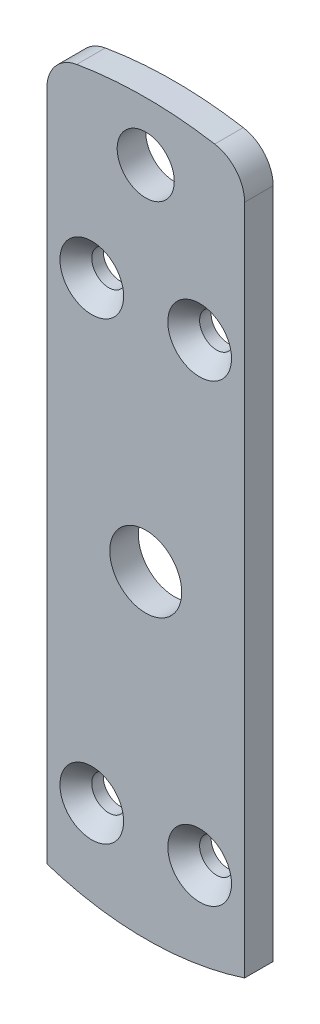
from build123d import *

# Parameters (mm, degrees)
SKETCH1_R                                      = 4
SKETCH1_R_2                                    = 3.175
BOSS_EXTRUDE1_DEPTH                            = 3.175
CSK_FOR_6_FLAT_HEAD_MACHINE_SCREW1_D           = 3.7973
CSK_FOR_6_FLAT_HEAD_MACHINE_SCREW1_DEPTH       = 10.973
CSK_FOR_6_FLAT_HEAD_MACHINE_SCREW1_CSINK_D     = 7.0866
CSK_FOR_6_FLAT_HEAD_MACHINE_SCREW1_CSINK_ANGLE = 82
CSK_FOR_6_FLAT_HEAD_MACHINE_SCREW1_TIP         = 1.140824014
FILLET1_R                                      = 4


with BuildPart() as part:
    # Sketch1 → Boss-Extrude1 (new body)
    with BuildSketch(Plane.XY):
        with BuildLine():
            Line((11, 44.330639799), (11, -33.647585352))
            ThreePointArc((11, -33.647585352), (0, -35.4), (-11, -33.647585352))
            Line((-11, -33.647585352), (-11, 44.330639799))
            ThreePointArc((-11, 44.330639799), (0, 45.675), (11, 44.330639799))
        make_face()
        Circle(SKETCH1_R, mode=Mode.SUBTRACT)
        with Locations((0, 39.175)):
            Circle(SKETCH1_R_2, mode=Mode.SUBTRACT)
    extrude(amount=BOSS_EXTRUDE1_DEPTH)

    # CSK for _6 Flat Head Machine Screw1
    with Locations(Plane.XY.offset(3.175)):
        with Locations((-6, 25.298221281), (-6, -25.298221281), (6, 25.298221281), (6, -25.298221281)):
            CounterSinkHole(CSK_FOR_6_FLAT_HEAD_MACHINE_SCREW1_D / 2, CSK_FOR_6_FLAT_HEAD_MACHINE_SCREW1_CSINK_D / 2, depth=CSK_FOR_6_FLAT_HEAD_MACHINE_SCREW1_DEPTH, counter_sink_angle=CSK_FOR_6_FLAT_HEAD_MACHINE_SCREW1_CSINK_ANGLE)
            with Locations((0, 0, -(CSK_FOR_6_FLAT_HEAD_MACHINE_SCREW1_DEPTH + CSK_FOR_6_FLAT_HEAD_MACHINE_SCREW1_TIP / 2))):  # 118° drill point
                Cone(0, CSK_FOR_6_FLAT_HEAD_MACHINE_SCREW1_D / 2, CSK_FOR_6_FLAT_HEAD_MACHINE_SCREW1_TIP, mode=Mode.SUBTRACT)

    # Fillet1
    fillet1_edges = [part.edges().sort_by_distance(p)[0] for p in [
        (-11, 44.330639799, 1.5875),
        (11, 44.330639799, 1.5875),
    ]]
    fillet(fillet1_edges, radius=FILLET1_R)


solid = part.part
